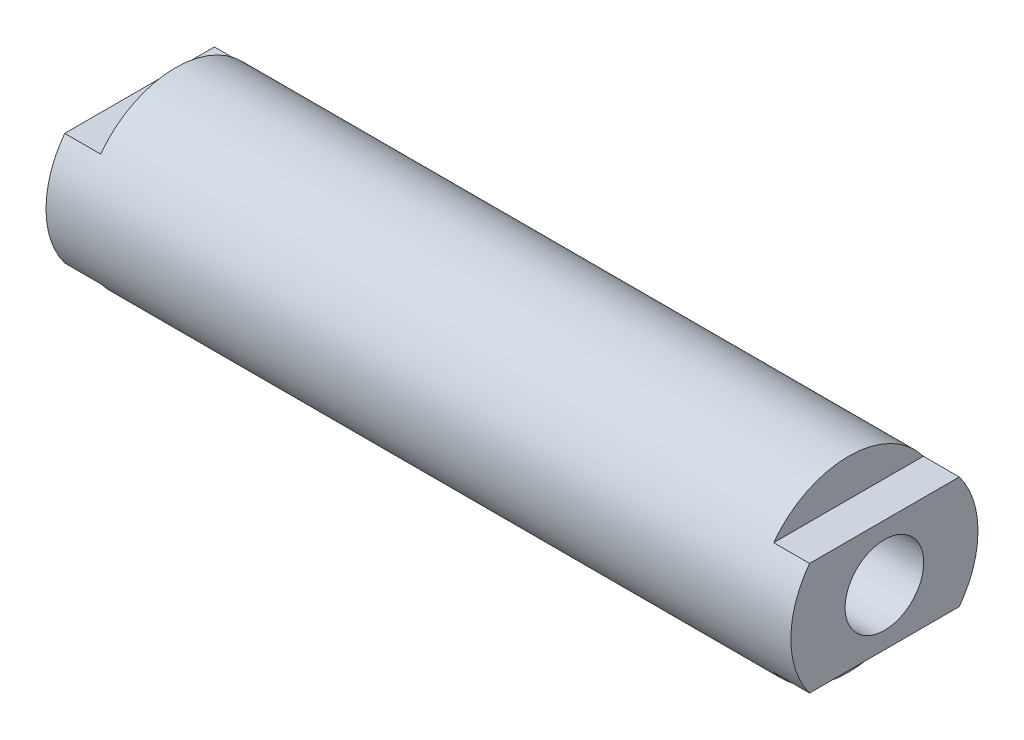
from build123d import *

# Parameters (mm, degrees)
ESQUISSE1_W               = 99.5
ESQUISSE1_H               = 12.5
ESQUISSE2_W               = 4.8
ESQUISSE2_H               = 5
ENL_V_MAT_EXTRU_1_DEPTH   = 13.5
SYM_TRIE2_COPY_1_SKETCH_W = 4.8
SYM_TRIE2_COPY_1_SKETCH_H = 5
SYM_TRIE2_COPY_1_DEPTH    = 13.5


with BuildPart() as part:
    # Esquisse1 → Révolution1 (revolve)
    with BuildSketch(Plane.XY, mode=Mode.PRIVATE) as r_volution1_sk:
        with Locations((0, 6.25)):
            Rectangle(ESQUISSE1_W, ESQUISSE1_H)
    revolve(r_volution1_sk.sketch.rotate(Axis((-69.457729469, 0, 0), (1, 0, 0)), 90), axis=Axis((-69.457729469, 0, 0), (1, 0, 0)))  # turned: the seam where the file's is

    # Esquisse2 → Enlèv. mat.-Extru.1 (cut, symmetric)
    with BuildSketch(Plane.XY):
        with Locations((-47.35, 10)):
            Rectangle(ESQUISSE2_W, ESQUISSE2_H)
    enl_v_mat_extru_1 = extrude(amount=ENL_V_MAT_EXTRU_1_DEPTH, both=True, mode=Mode.SUBTRACT)

    # Symétrie1: Enlèv. mat.-Extru.1 across plane
    add(enl_v_mat_extru_1.mirror(Plane.ZX), mode=Mode.SUBTRACT)

    # Esquisse5 → Diamètre du perçage Ø10.5 (10.5)1 (revolve, cut)
    with BuildSketch(Plane(origin=(-49.75, 0, 0), x_dir=(0, 0, 1), z_dir=(0, 1, 0))):
        Polygon((0, 0), (0, 36.15451825), (5.25, 33), (5.25, 0), align=None)
    diam_tre_du_per_age_10_5_10_5_1 = revolve(axis=Axis((-56.1, 0, 0), (1, 0, 0)), mode=Mode.SUBTRACT)

    # Symétrie2: Diamètre du perçage Ø10.5 (10.5)1, Enlèv. mat.-Extru.1 across plane
    add(diam_tre_du_per_age_10_5_10_5_1.mirror(Plane(origin=(0, 0, 0), x_dir=(0, 0, 1), z_dir=(1, 0, 0))), mode=Mode.SUBTRACT)
    add(enl_v_mat_extru_1.mirror(Plane(origin=(0, 0, 0), x_dir=(0, 0, 1), z_dir=(1, 0, 0))), mode=Mode.SUBTRACT)

    # Symétrie2 copy 1 sketch → Symétrie2 copy 1 (cut, symmetric)
    with BuildSketch(Plane(origin=(0, 0, 0), x_dir=(-1, 0, 0), z_dir=(0, 0, 1))):
        with Locations((-47.35, 10)):
            Rectangle(SYM_TRIE2_COPY_1_SKETCH_W, SYM_TRIE2_COPY_1_SKETCH_H)
    extrude(amount=SYM_TRIE2_COPY_1_DEPTH, both=True, mode=Mode.SUBTRACT)


solid = part.part
